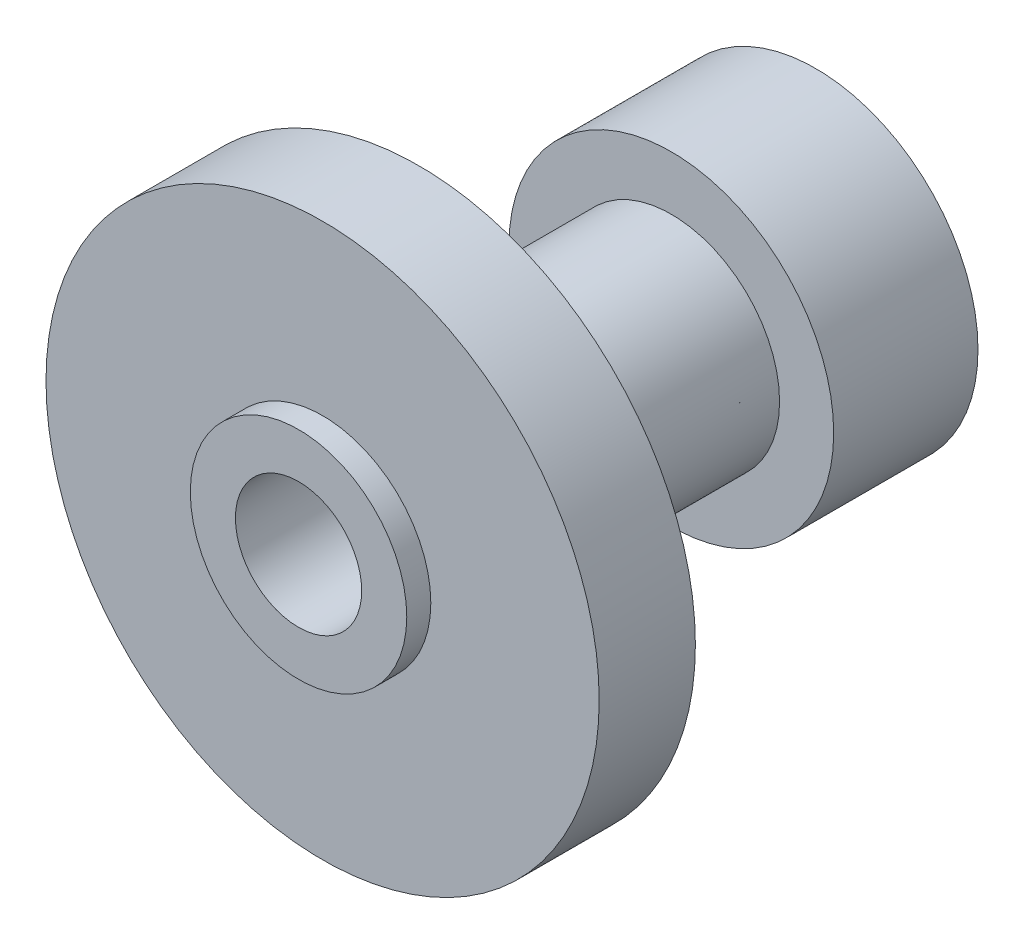
from build123d import *

# Parameters (mm, degrees)
SKETCH_1_R          = 23
EXTRUDE_1_DEPTH     = 8
SKETCH_2_R          = 9
EXTRUDE_2_DEPTH     = 2
SKETCH_3_R          = 9
EXTRUDE_3_DEPTH     = 21
SKETCH_4_R          = 13.5
EXTRUDE_4_DEPTH     = 12
SKETCH_5_R          = 7.5
CUT_EXTRUDE_1_DEPTH = 4
SKETCH_6_R          = 5.25
CUT_EXTRUDE_2_DEPTH = 100


with BuildPart() as part:
    # Эскиз1 → Бобышка-Вытянуть1 (new body)
    with BuildSketch(Plane.XY):
        Circle(SKETCH_1_R)
    extrude(amount=EXTRUDE_1_DEPTH)

    # Эскиз2 → Бобышка-Вытянуть2 (add)
    with BuildSketch(Plane.XY.offset(8)):
        Circle(SKETCH_2_R)
    extrude(amount=EXTRUDE_2_DEPTH)

    # Эскиз3 → Бобышка-Вытянуть3 (add)
    with BuildSketch(Plane(origin=(0, 0, 0), x_dir=(-1, 0, 0), z_dir=(0, 0, -1))):
        Circle(SKETCH_3_R)
    extrude(amount=EXTRUDE_3_DEPTH)

    # Эскиз4 → Бобышка-Вытянуть4 (add)
    with BuildSketch(Plane(origin=(0, 0, -21), x_dir=(-1, 0, 0), z_dir=(0, 0, -1))):
        Circle(SKETCH_4_R)
    extrude(amount=EXTRUDE_4_DEPTH)

    # Эскиз5 → Вырез-Вытянуть1 (cut)
    with BuildSketch(Plane(origin=(0, 0, -33), x_dir=(-1, 0, 0), z_dir=(0, 0, -1))):
        Circle(SKETCH_5_R)
    extrude(amount=-CUT_EXTRUDE_1_DEPTH, mode=Mode.SUBTRACT)

    # Эскиз6 → Вырез-Вытянуть2 (cut)
    with BuildSketch(Plane(origin=(0, 0, -29), x_dir=(-1, 0, 0), z_dir=(0, 0, -1))):
        Circle(SKETCH_6_R)
    extrude(amount=-CUT_EXTRUDE_2_DEPTH, mode=Mode.SUBTRACT)


solid = part.part
